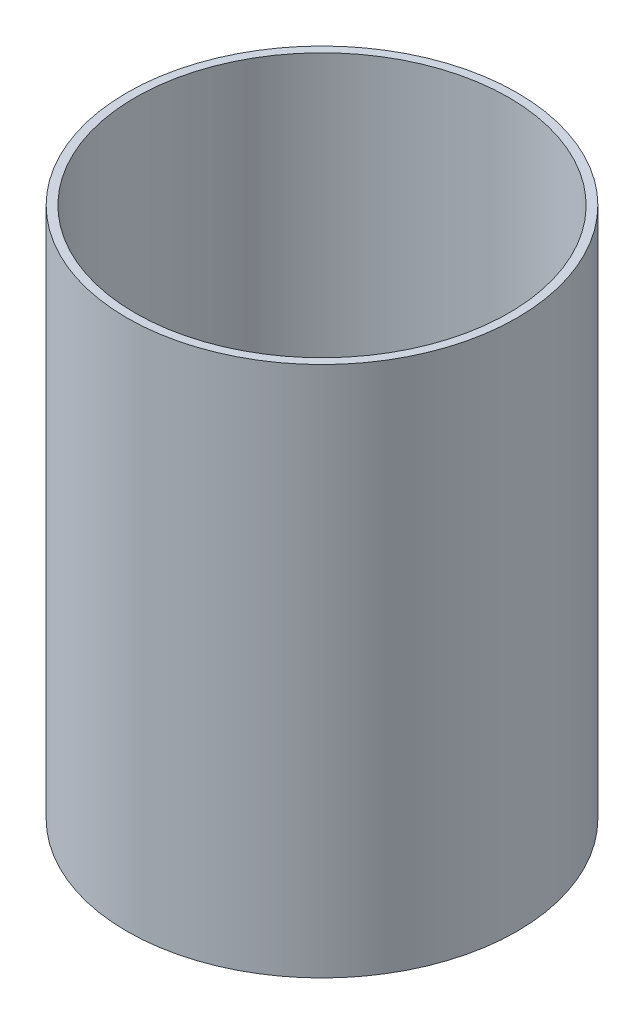
from build123d import *

# Parameters (mm, degrees)
SKETCH1_R           = 149.225
SKETCH1_R_2         = 142.875
BOSS_EXTRUDE1_DEPTH = 406.4


with BuildPart() as part:
    # Sketch1 → Boss-Extrude1 (new body)
    with BuildSketch(Plane(origin=(0, 0, 0), x_dir=(1, 0, 0), z_dir=(0, 1, 0))):
        Circle(SKETCH1_R)
        Circle(SKETCH1_R_2, mode=Mode.SUBTRACT)
    extrude(amount=BOSS_EXTRUDE1_DEPTH)


solid = part.part
